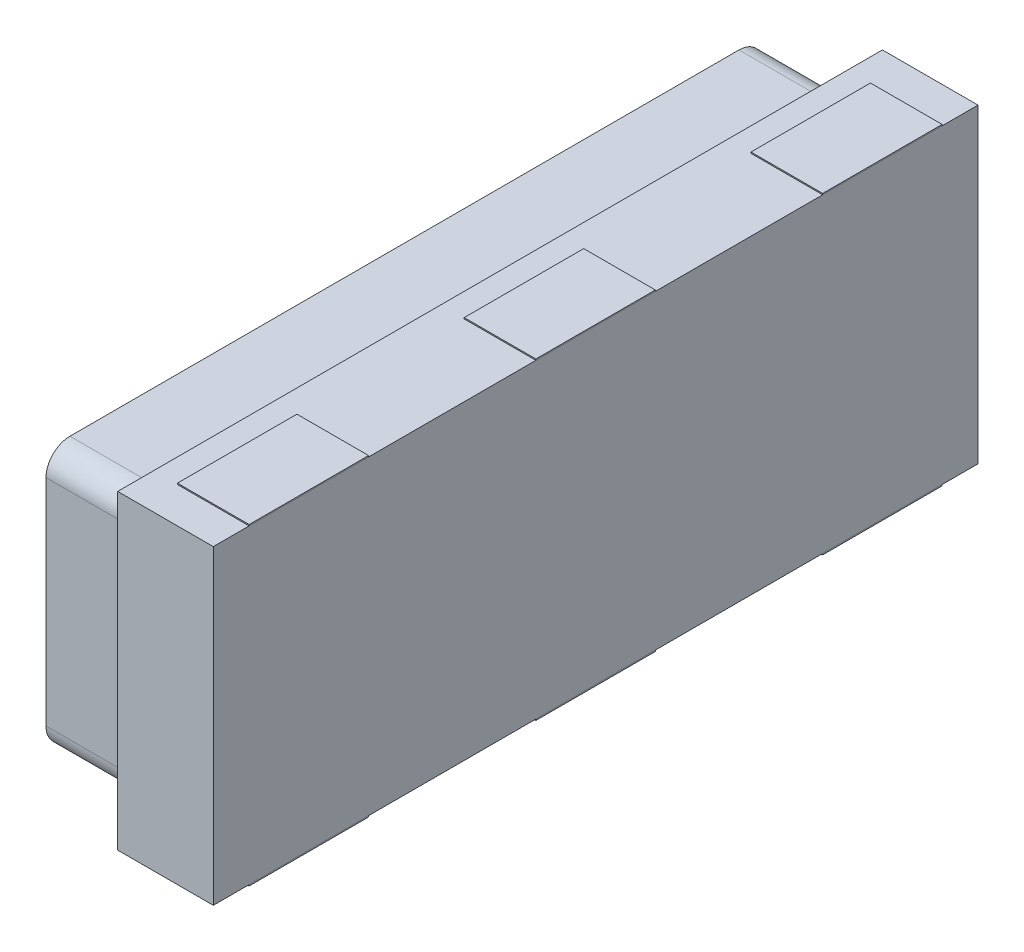
from build123d import *

# Parameters (mm, degrees)
SKETCH_1_W        = 3.2
SKETCH_1_H        = 1.3
EXTRUDE_1_DEPTH   = 0.4
EXTRUDE_2_DEPTH   = 0.4
SKETCH_3_W        = 0.5
SKETCH_3_H        = 1.31
EXTRUDE_3_DEPTH   = 0.3
EXTRUDE_3_2_DEPTH = 0.3
EXTRUDE_3_3_DEPTH = 0.3


with BuildPart() as part:
    # Эскиз1 → Бобышка-Вытянуть1 (new body)
    with BuildSketch(Plane(origin=(0, 0, 0), x_dir=(0, 0, -1), z_dir=(1, 0, 0))):
        Rectangle(SKETCH_1_W, SKETCH_1_H)
    extrude(amount=EXTRUDE_1_DEPTH)


with BuildPart() as body_2:
    # Эскиз2 → Бобышка-Вытянуть2 (new body)
    with BuildSketch(Plane.ZY):
        with BuildLine():
            Line((-1.4, 0.55), (1.4, 0.55))
            ThreePointArc((1.4, 0.55), (1.470710678, 0.520710678), (1.5, 0.45))
            Line((1.5, 0.45), (1.5, -0.45))
            ThreePointArc((1.5, -0.45), (1.470710678, -0.520710678), (1.4, -0.55))
            Line((1.4, -0.55), (-1.4, -0.55))
            ThreePointArc((-1.4, -0.55), (-1.470710678, -0.520710678), (-1.5, -0.45))
            Line((-1.5, -0.45), (-1.5, 0.45))
            ThreePointArc((-1.5, 0.45), (-1.470710678, 0.520710678), (-1.4, 0.55))
        make_face()
    extrude(amount=EXTRUDE_2_DEPTH)


with BuildPart() as body_3:
    # Эскиз3 → Бобышка-Вытянуть3 (new body)
    with BuildSketch(Plane(origin=(0.4, 0, 0), x_dir=(0, 0, -1), z_dir=(1, 0, 0))):
        Rectangle(SKETCH_3_W, SKETCH_3_H)
    extrude(amount=-EXTRUDE_3_DEPTH)


with BuildPart() as body_4:
    # Эскиз3 → Extrude 3 2 (new body)
    with BuildSketch(Plane(origin=(0.4, 0, 0), x_dir=(0, 0, -1), z_dir=(1, 0, 0))):
        with Locations((1.2, 0)):
            Rectangle(SKETCH_3_W, SKETCH_3_H)
    extrude(amount=-EXTRUDE_3_2_DEPTH)


with BuildPart() as body_5:
    # Эскиз3 → Extrude 3 3 (new body)
    with BuildSketch(Plane(origin=(0.4, 0, 0), x_dir=(0, 0, -1), z_dir=(1, 0, 0))):
        with Locations((-1.2, 0)):
            Rectangle(SKETCH_3_W, SKETCH_3_H)
    extrude(amount=-EXTRUDE_3_3_DEPTH)


solid = Compound([part.part, body_2.part, body_3.part, body_4.part, body_5.part])
